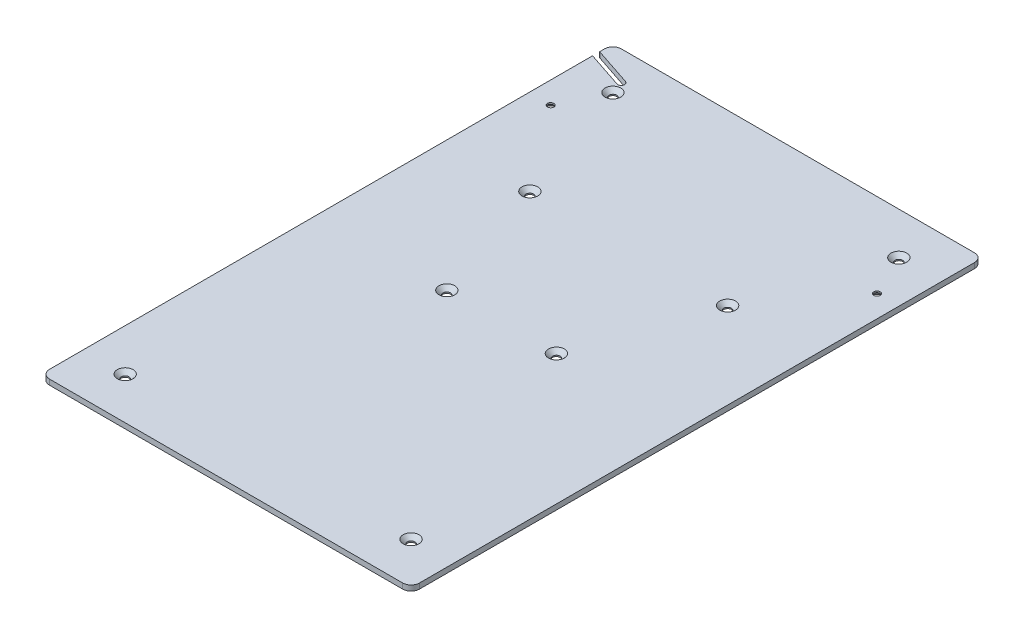
from build123d import *

# Parameters (mm, degrees)
SKETCH1_W                                      = 220
SKETCH1_H                                      = 340
BOSS_EXTRUDE1_DEPTH                            = 3.175
FILLET1_R                                      = 5
CSK_FOR_6_FLAT_HEAD_SOCKET_CAP_SCREW1_A_COUNT  = 2
CSK_FOR_6_FLAT_HEAD_SOCKET_CAP_SCREW1_A_PITCH  = 194
CSK_FOR_M4_FLAT_HEAD_MACHINE_SCREW1_AT_2_COUNT = 2
CSK_FOR_M4_FLAT_HEAD_MACHINE_SCREW1_AT_2_PITCH = 148.413565465
CSK_FOR_M4_FLAT_HEAD_MACHINE_SCREW1_AT_3_COUNT = 2
CSK_FOR_M4_FLAT_HEAD_MACHINE_SCREW1_AT_3_PITCH = 216.016881764
CSK_FOR_M4_FLAT_HEAD_MACHINE_SCREW1_AT_4_COUNT = 2
CSK_FOR_M4_FLAT_HEAD_MACHINE_SCREW1_AT_4_PITCH = 290
CUT_EXTRUDE1_DEPTH                             = 4.175


with BuildPart() as part:
    # Sketch1 → Boss-Extrude1 (new body)
    with BuildSketch(Plane(origin=(0, 0, 0), x_dir=(1, 0, 0), z_dir=(0, 1, 0))):
        Rectangle(SKETCH1_W, SKETCH1_H)
    extrude(amount=BOSS_EXTRUDE1_DEPTH)

    # Fillet1
    fillet1_edges = [part.edges().sort_by_distance(p)[0] for p in [
        (-110, 1.5875, -170),
        (110, 1.5875, -170),
        (110, 1.5875, 170),
        (-110, 1.5875, 170),
    ]]
    fillet(fillet1_edges, radius=FILLET1_R)

    # Sketch4 → CSK for #6 Flat Head Socket Cap Screw1 (revolve, cut)
    with BuildSketch(Plane(origin=(97, 0, -120), x_dir=(0, 0, -1), z_dir=(1, 0, 0))):
        Polygon((0, 0), (0, 3.175), (1.89865, 3.175), (1.89865, 2.301024407), (3.8989, 0), align=None)
    csk_for_6_flat_head_socket_cap_screw1 = revolve(axis=Axis((97, -6.35, -120), (0, 1, 0)), mode=Mode.SUBTRACT)

    # CSK for #6 Flat Head Socket Cap Screw1 a: CSK for #6 Flat Head Socket Cap Screw1 ×2
    with Locations(*[(-i * CSK_FOR_6_FLAT_HEAD_SOCKET_CAP_SCREW1_A_PITCH, 0, 0) for i in range(1, CSK_FOR_6_FLAT_HEAD_SOCKET_CAP_SCREW1_A_COUNT)]):
        add(csk_for_6_flat_head_socket_cap_screw1, mode=Mode.SUBTRACT)

    # Sketch5 → CSK for M4 Flat Head Machine Screw1 (revolve, cut)
    with BuildSketch(Plane(origin=(-85, 3.175, 145), x_dir=(0, 0, 1), z_dir=(1, 0, 0))):
        Polygon((0, 0), (0, 3.175), (2.25, 3.175), (2.25, 2.45), (4.7, 0), align=None)
    csk_for_m4_flat_head_machine_screw1 = revolve(axis=Axis((-85, 9.525, 145), (0, -1, 0)), mode=Mode.SUBTRACT)

    # CSK for M4 Flat Head Machine Screw1 at 2: CSK for M4 Flat Head Machine Screw1 ×2
    with Locations(*[Vector(0.353361448, 0, -0.935486872) * (i * CSK_FOR_M4_FLAT_HEAD_MACHINE_SCREW1_AT_2_PITCH) for i in range(1, CSK_FOR_M4_FLAT_HEAD_MACHINE_SCREW1_AT_2_COUNT)]):
        add(csk_for_m4_flat_head_machine_screw1, mode=Mode.SUBTRACT)

    # CSK for M4 Flat Head Machine Screw1 at 3: CSK for M4 Flat Head Machine Screw1 ×2
    with Locations(*[Vector(0.12138781, 0, -0.992605158) * (i * CSK_FOR_M4_FLAT_HEAD_MACHINE_SCREW1_AT_3_PITCH) for i in range(1, CSK_FOR_M4_FLAT_HEAD_MACHINE_SCREW1_AT_3_COUNT)]):
        add(csk_for_m4_flat_head_machine_screw1, mode=Mode.SUBTRACT)

    # CSK for M4 Flat Head Machine Screw1 at 4: CSK for M4 Flat Head Machine Screw1 ×2
    with Locations(*[(0, 0, -i * CSK_FOR_M4_FLAT_HEAD_MACHINE_SCREW1_AT_4_PITCH) for i in range(1, CSK_FOR_M4_FLAT_HEAD_MACHINE_SCREW1_AT_4_COUNT)]):
        add(csk_for_m4_flat_head_machine_screw1, mode=Mode.SUBTRACT)

    # Mirror1: CSK for M4 Flat Head Machine Screw1 across plane
    add(csk_for_m4_flat_head_machine_screw1.mirror(Plane(origin=(0, 0, 0), x_dir=(0, 0, 1), z_dir=(1, 0, 0))), mode=Mode.SUBTRACT)

    # Mirror1 copy 1 sketch → Mirror1 copy 1 (revolve, cut)
    with BuildSketch(Plane(origin=(32.556367665, 3.175, 6.161057907), x_dir=(0, 0, 1), z_dir=(-1, 0, 0))):
        Polygon((0, 0), (0, -3.175), (2.25, -3.175), (2.25, -2.45), (4.7, 0), align=None)
    revolve(axis=Axis((32.556367665, 9.525, 6.161057907), (0, 1, 0)), mode=Mode.SUBTRACT)

    # Mirror1 copy 2 sketch → Mirror1 copy 2 (revolve, cut)
    with BuildSketch(Plane(origin=(58.778183832, 3.175, -69.419471047), x_dir=(0, 0, 1), z_dir=(-1, 0, 0))):
        Polygon((0, 0), (0, -3.175), (2.25, -3.175), (2.25, -2.45), (4.7, 0), align=None)
    revolve(axis=Axis((58.778183832, 9.525, -69.419471047), (0, 1, 0)), mode=Mode.SUBTRACT)

    # Mirror1 copy 3 sketch → Mirror1 copy 3 (revolve, cut)
    with BuildSketch(Plane(origin=(85, 3.175, -145), x_dir=(0, 0, 1), z_dir=(-1, 0, 0))):
        Polygon((0, 0), (0, -3.175), (2.25, -3.175), (2.25, -2.45), (4.7, 0), align=None)
    revolve(axis=Axis((85, 9.525, -145), (0, 1, 0)), mode=Mode.SUBTRACT)

    # Sketch7 → Cut-Extrude1 (cut, through all)
    with BuildSketch(Plane(origin=(0, 3.175, 0), x_dir=(1, 0, 0), z_dir=(0, 1, 0))):
        with BuildLine():
            Line((-109.368867035, 161.89780694), (-86.991048652, 154.455859835))
            ThreePointArc((-86.991048652, 154.455859835), (-85.724374677, 151.926919931), (-88.253314582, 150.660245956))
            Line((-88.253314582, 150.660245956), (-110.631132965, 158.10219306))
            ThreePointArc((-110.631132965, 158.10219306), (-111.89780694, 160.631132965), (-109.368867035, 161.89780694))
        make_face()
    extrude(amount=-CUT_EXTRUDE1_DEPTH, mode=Mode.SUBTRACT)


solid = part.part
